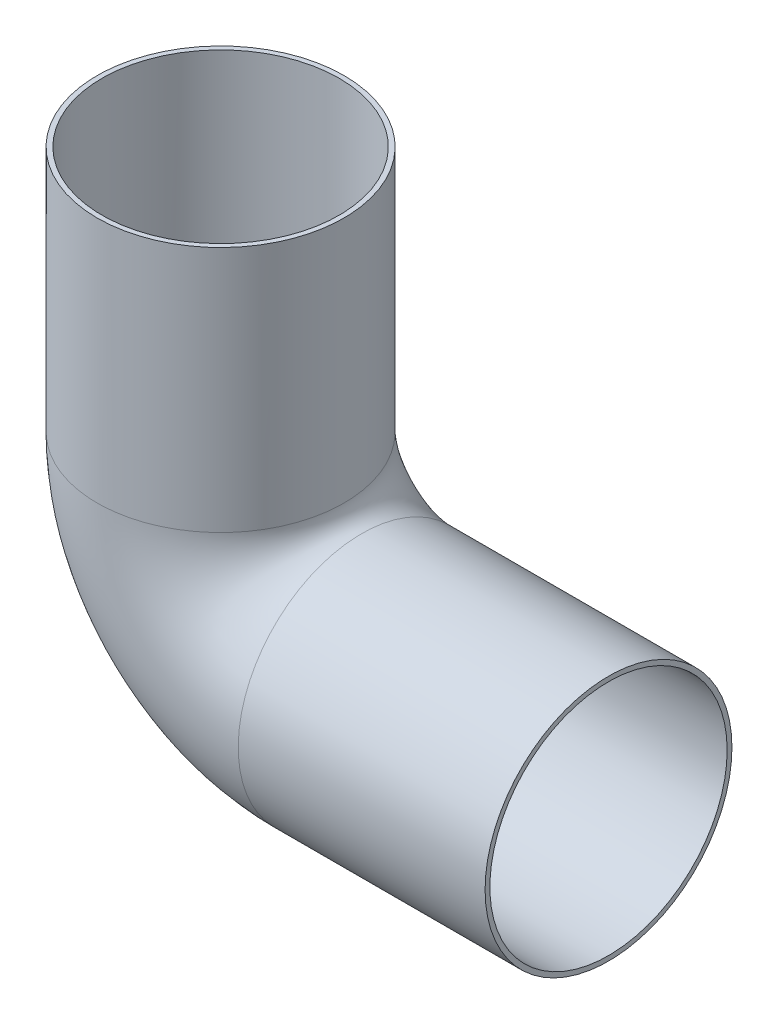
from build123d import *

# Parameters (mm, degrees)
SKETCH2_R   = 11.1125
SKETCH2_R_2 = 10.6807


with BuildPart() as part:
    # Sweep1: sweep along a path in Sketch1
    with BuildLine(Plane.XY) as sweep1_path:
        Line((-17.4625, 17.792757526), (-17.4625, -4.432242474))
        ThreePointArc((-17.4625, -4.432242474), (-13.742756121, -13.412498595), (-4.7625, -17.132242474))
        Line((-4.7625, -17.132242474), (17.4625, -17.132242474))
    # Sketch2 → Sweep1 (sweep)
    with BuildSketch(Plane(origin=(17.4625, -17.132242474, 0), x_dir=(0, 0, -1), z_dir=(1, 0, 0))):
        Circle(SKETCH2_R)
        Circle(SKETCH2_R_2, mode=Mode.SUBTRACT)
    sweep(path=sweep1_path.line)


solid = part.part
